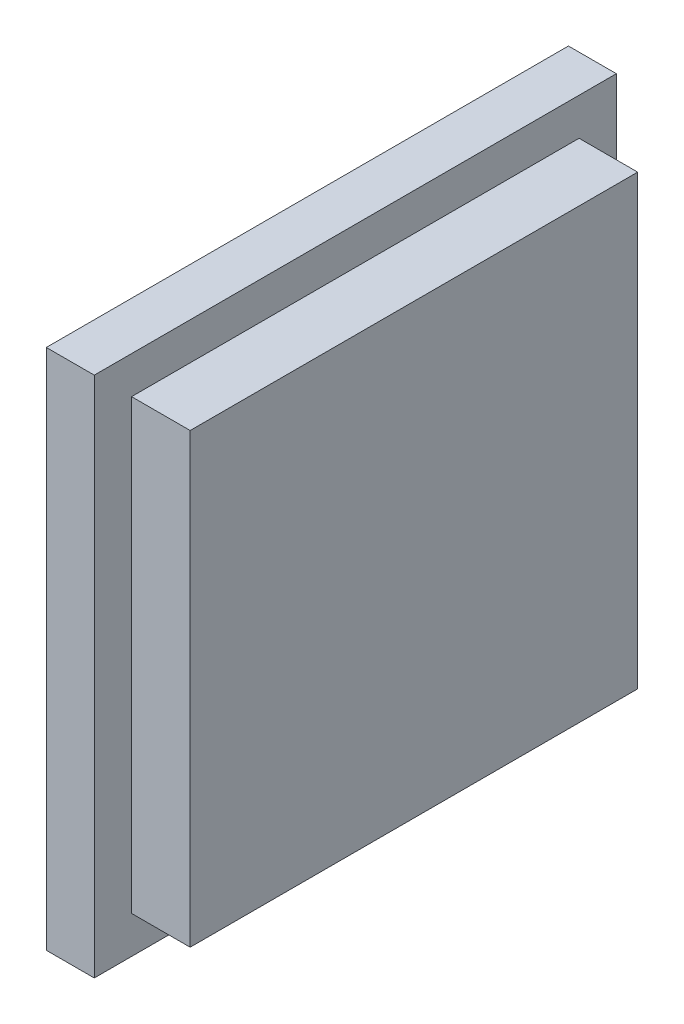
from build123d import *

# Parameters (mm, degrees)
SKETCH1_W           = 49
SKETCH1_H           = 49
BOSS_EXTRUDE1_DEPTH = 4.5
SKETCH3_W           = 42
SKETCH3_H           = 42
BOSS_EXTRUDE3_DEPTH = 5.5


with BuildPart() as part:
    # Sketch1 → Boss-Extrude1 (new body)
    with BuildSketch(Plane(origin=(0, 0, 0), x_dir=(0, 0, -1), z_dir=(1, 0, 0))):
        Rectangle(SKETCH1_W, SKETCH1_H)
    extrude(amount=BOSS_EXTRUDE1_DEPTH)

    # Sketch3 → Boss-Extrude3 (add)
    with BuildSketch(Plane(origin=(4.5, 0, 0), x_dir=(0, 0, -1), z_dir=(1, 0, 0))):
        Rectangle(SKETCH3_W, SKETCH3_H)
    extrude(amount=BOSS_EXTRUDE3_DEPTH)


solid = part.part
